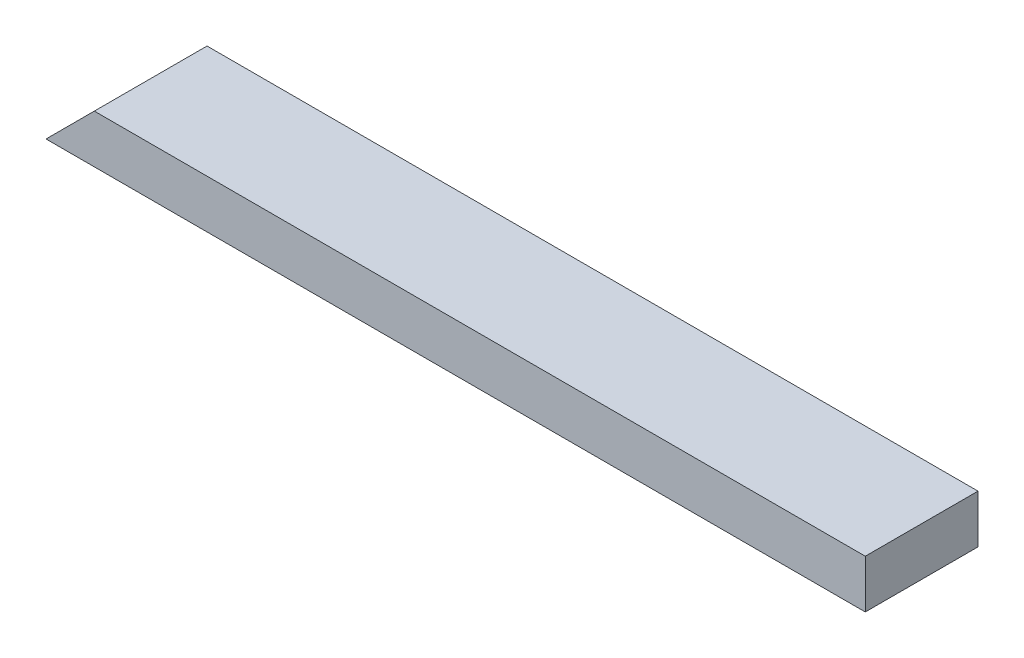
from build123d import *

# Parameters (mm, degrees)
SKETCH1_W           = 646.1125
SKETCH1_H           = 88.9
BOSS_EXTRUDE1_DEPTH = 38.1
CUT_EXTRUDE1_DEPTH  = 89.9


with BuildPart() as part:
    # Sketch1 → Boss-Extrude1 (new body)
    with BuildSketch(Plane(origin=(0, 0, 0), x_dir=(1, 0, 0), z_dir=(0, 1, 0))):
        with Locations((323.05625, 44.45)):
            Rectangle(SKETCH1_W, SKETCH1_H)
    extrude(amount=BOSS_EXTRUDE1_DEPTH)

    # Sketch2 → Cut-Extrude1 (cut, through all)
    with BuildSketch(Plane.XY):
        Polygon((0, 0), (38.1, 38.1), (0, 38.1), align=None)
    extrude(amount=-CUT_EXTRUDE1_DEPTH, mode=Mode.SUBTRACT)


solid = part.part
